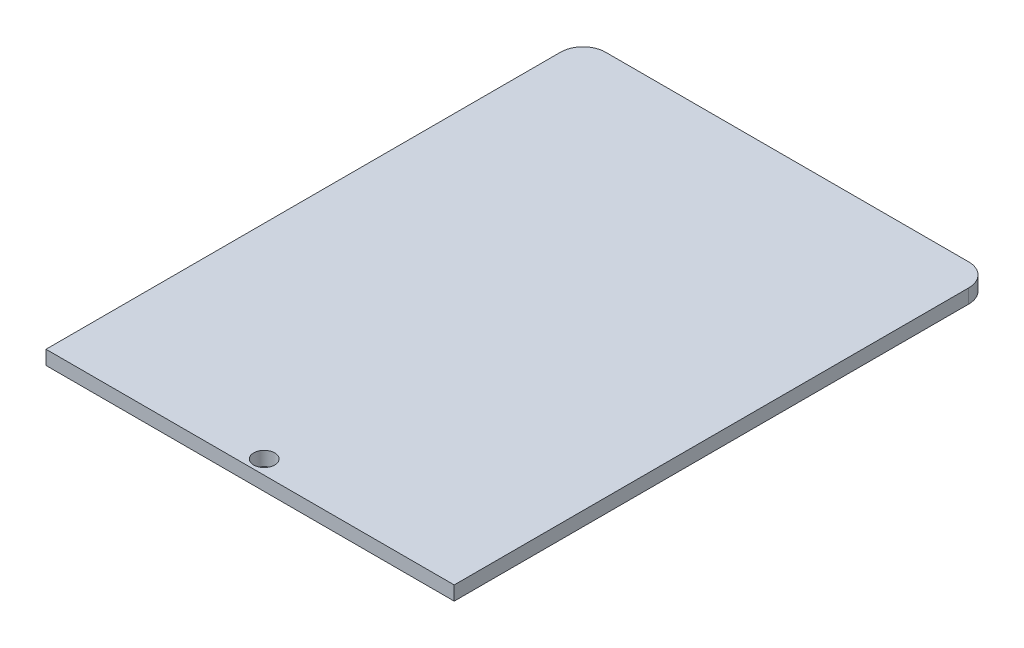
from build123d import *

# Parameters (mm, degrees)
SKETCH1_R           = 1.190625
BOSS_EXTRUDE1_DEPTH = 1.5875


with BuildPart() as part:
    # Sketch1 → Boss-Extrude1 (new body)
    with BuildSketch(Plane(origin=(0, 0, 0), x_dir=(1, 0, 0), z_dir=(0, 1, 0))):
        with BuildLine():
            Line((2.54, 60.579), (43.50625616, 60.579))
            ThreePointArc((43.50625616, 60.579), (45.302307384, 59.835051224), (46.04625616, 58.039))
            Line((46.04625616, 58.039), (46.04625616, 0))
            Line((46.04625616, 0), (0, 0))
            Line((0, 0), (0, 58.039))
            ThreePointArc((0, 58.039), (0.743948776, 59.835051224), (2.54, 60.579))
        make_face()
        with Locations((23.02312808, 1.5875)):
            Circle(SKETCH1_R, mode=Mode.SUBTRACT)
    extrude(amount=BOSS_EXTRUDE1_DEPTH)


solid = part.part
